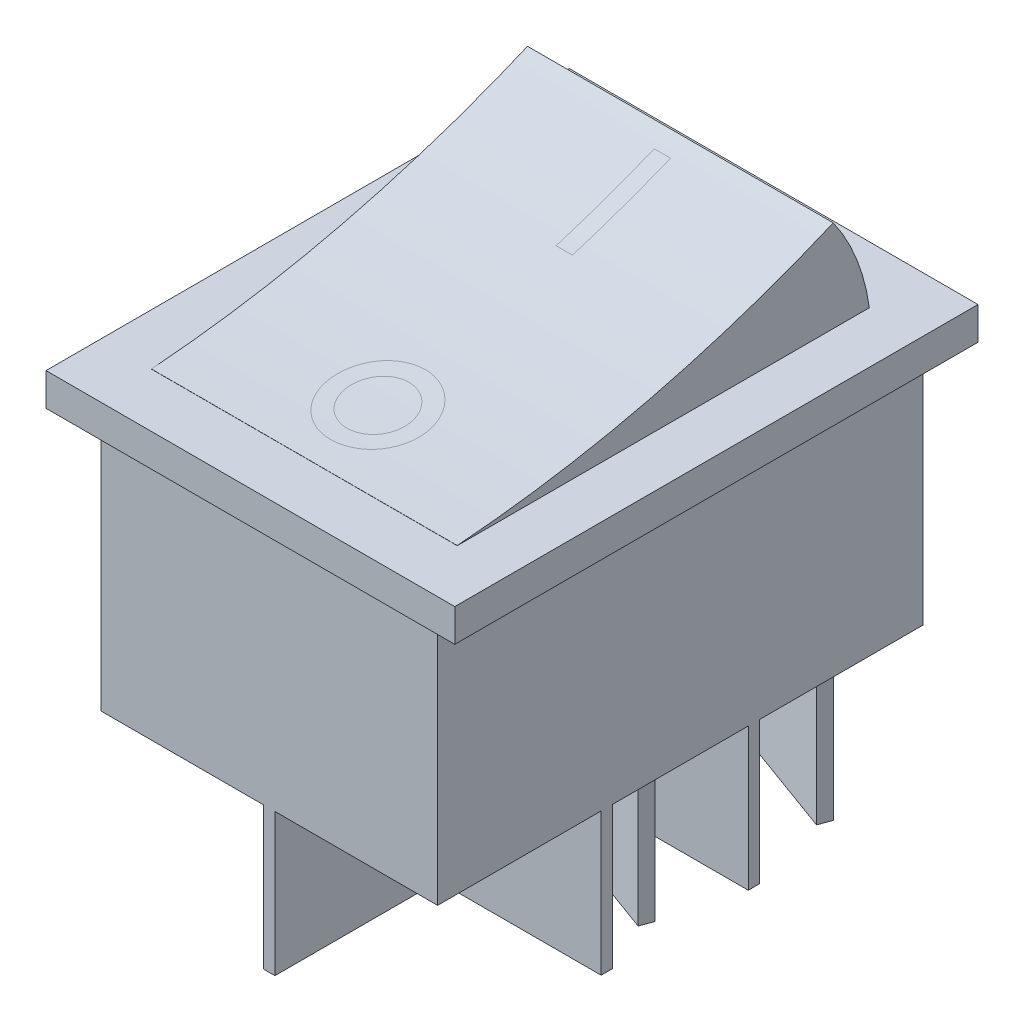
from build123d import *

# Parameters (mm, degrees)
EXTRUDE1_DEPTH     = 14.85
SKETCH2_W          = 25
SKETCH2_H          = 2
EXTRUDE2_DEPTH     = 1.15
EXTRUDE4_DEPTH     = 9.35
SKETCH5_W          = 9.95
SKETCH5_H          = 10
SKETCH5_H_2        = 8.3
CUT_EXTRUDE1_DEPTH = 8.7
EXTRUDE5_DEPTH     = 9.3


with BuildPart() as part:
    # Sketch1 → Extrude1 (new body, symmetric)
    with BuildSketch(Plane.XY):
        Polygon((12.5, 26.2), (-12.5, 26.2), (-12.5, 24.2), (-10.3, 24.2), (-10.3, 0), (10.3, 0), (10.3, 24.2), (12.5, 24.2), align=None)
    extrude(amount=EXTRUDE1_DEPTH, both=True)

    # Sketch2 → Extrude2 (add)
    with BuildSketch(Plane.XY.offset(14.85)):
        with Locations((0, 25.2)):
            Rectangle(SKETCH2_W, SKETCH2_H)
    extrude2 = extrude(amount=EXTRUDE2_DEPTH)

    # Mirror1: Extrude2 across plane
    add(extrude2.mirror(Plane.XY))

    # Sketch4 → Extrude4 (add, symmetric)
    with BuildSketch(Plane(origin=(0, 0, 0), x_dir=(0, 0, -1), z_dir=(1, 0, 0))):
        with BuildLine():
            Line((-12.7, 26.2), (-12.7, 26.21))
            ThreePointArc((-12.7, 26.21), (-0.971928332, 28.066601365), (10.3, 31.8))
            ThreePointArc((10.3, 31.8), (11.738824473, 29.133109614), (12.5, 26.2))
            Line((12.5, 26.2), (-12.7, 26.2))
        make_face()
    extrude(amount=EXTRUDE4_DEPTH, both=True)

    # Sketch5 → Cut-Extrude1 (cut)
    with BuildSketch(Plane.XZ):
        with Locations((5.325, 9.85)):
            Rectangle(SKETCH5_W, SKETCH5_H)
        with Locations((5.325, 0)):
            Rectangle(SKETCH5_W, SKETCH5_H_2)
        with Locations((-5.325, 9.85)):
            Rectangle(SKETCH5_W, SKETCH5_H)
        with Locations((-5.325, -9.85)):
            Rectangle(SKETCH5_W, SKETCH5_H)
        with Locations((5.325, -9.85)):
            Rectangle(SKETCH5_W, SKETCH5_H)
        with Locations((-5.325, 0)):
            Rectangle(SKETCH5_W, SKETCH5_H_2)
    extrude(amount=-CUT_EXTRUDE1_DEPTH, mode=Mode.SUBTRACT)

    # Sketch9 → Extrude5 (add)
    with BuildSketch(Plane.XZ.offset(-8.7)):
        Polygon((-8.145589208, -13.205654355), (-2.225525697, -11.050927452), (-2.499141811, -10.299173355), (-8.419205322, -12.453900258), align=None)
        Polygon((2.678569935, -13.205654355), (8.598633446, -11.050927452), (8.325017331, -10.299173355), (2.40495382, -12.453900258), align=None)
        Polygon((-8.241705742, -2.392544248), (-2.321642231, -0.237817345), (-2.595258346, 0.513936752), (-8.515321856, -1.640790151), align=None)
        Polygon((2.582453401, -2.392544248), (8.502516912, -0.237817345), (8.228900797, 0.513936752), (2.308837286, -1.640790151), align=None)
    extrude(amount=EXTRUDE5_DEPTH)


solid = part.part
